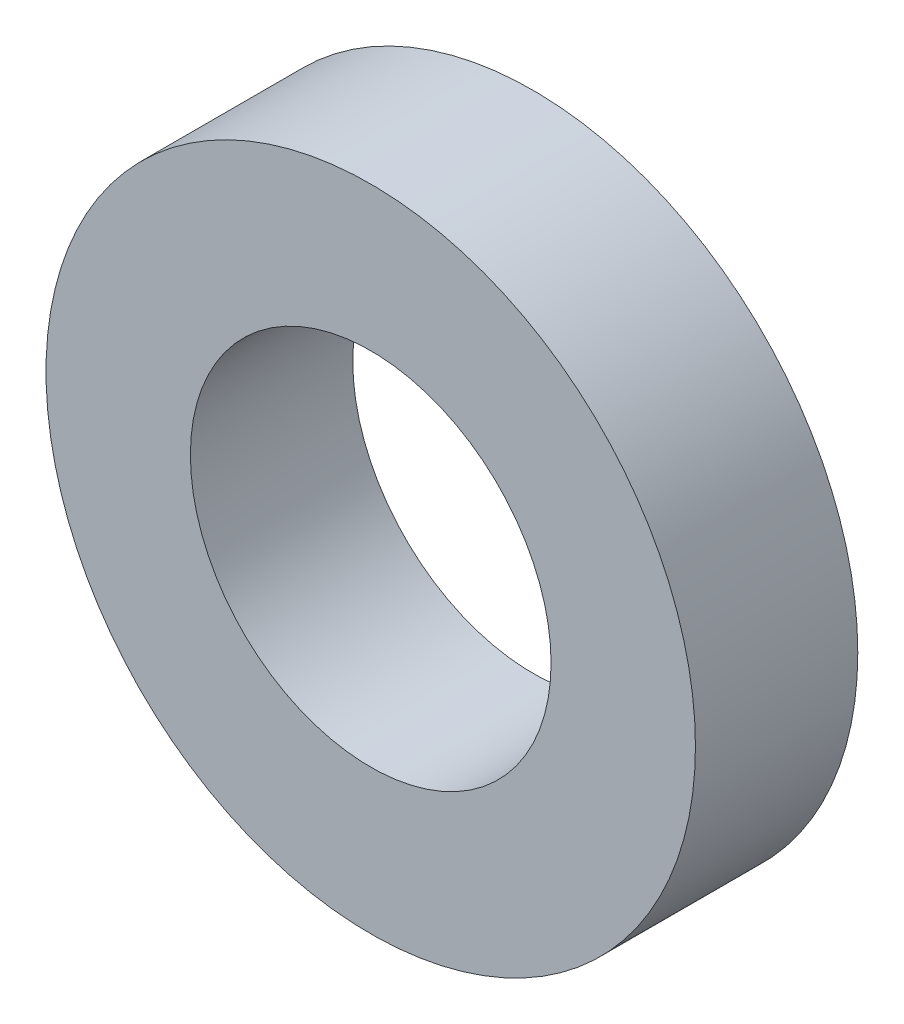
from build123d import *

# Parameters (mm, degrees)
SKETCH_1_R          = 100
EXTRUDE_1_DEPTH     = 50
SKETCH_2_R          = 55.538245615
CUT_EXTRUDE_1_DEPTH = 51


with BuildPart() as part:
    # Эскиз1 → Бобышка-Вытянуть1 (new body)
    with BuildSketch(Plane.XY):
        Circle(SKETCH_1_R)
    extrude(amount=EXTRUDE_1_DEPTH)

    # Эскиз2 → Вырез-Вытянуть1 (cut, through all)
    with BuildSketch(Plane.XY.offset(50)):
        Circle(SKETCH_2_R)
    extrude(amount=-CUT_EXTRUDE_1_DEPTH, mode=Mode.SUBTRACT)


solid = part.part
